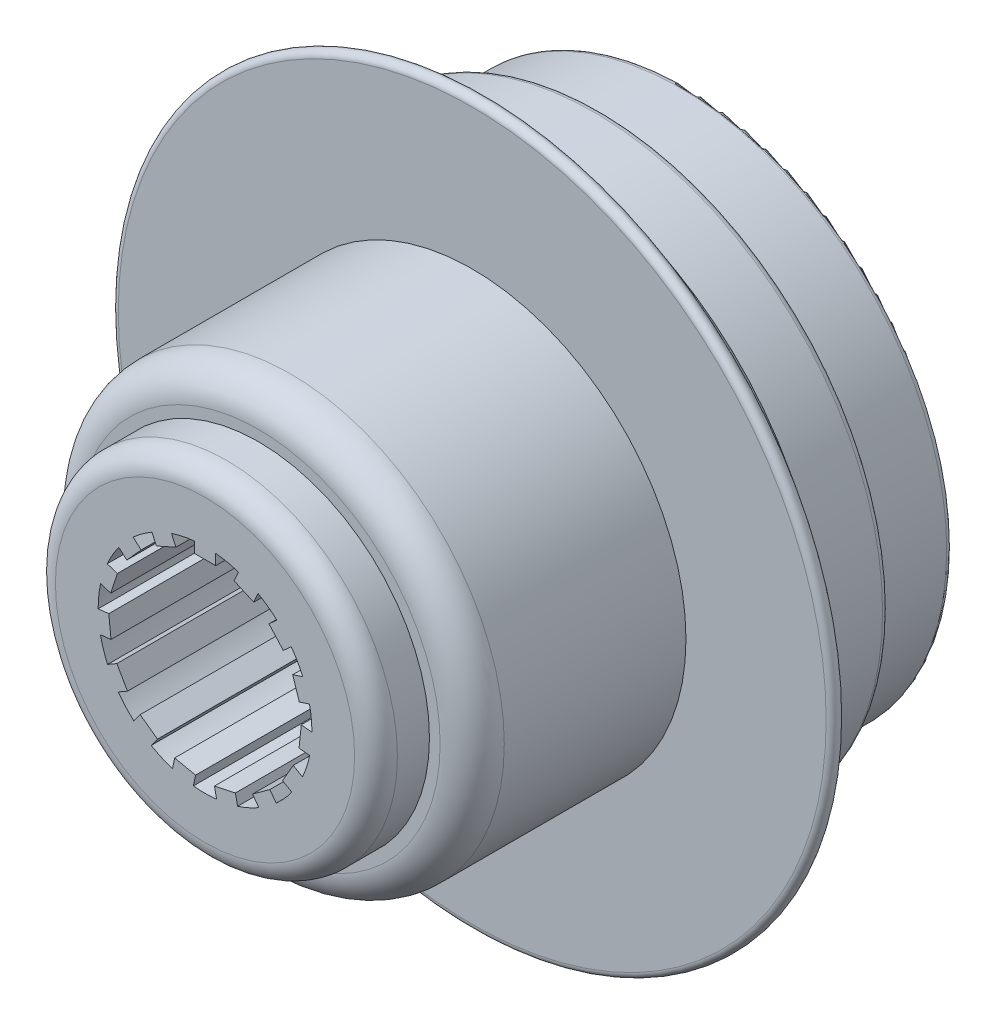
from build123d import *

# Parameters (mm, degrees)
SKETCH2_R          = 19.05
CUT_EXTRUDE1_DEPTH = 10.16
CUT_EXTRUDE4_DEPTH = 35.56


with BuildPart() as part:
    # Sketch1 → Revolve1 (revolve)
    with BuildSketch(Plane(origin=(0, 0, 0), x_dir=(0, 0, -1), z_dir=(1, 0, 0))):
        with BuildLine():
            Line((25.4, 0), (25.4, 30.988))
            ThreePointArc((25.4, 30.988), (25.176815367, 31.526815367), (24.638, 31.75))
            Line((24.638, 31.75), (15.24, 31.75))
            Line((15.24, 31.75), (15.24, 33.528))
            ThreePointArc((15.24, 33.528), (15.016815367, 34.066815367), (14.478, 34.29))
            Line((14.478, 34.29), (7.405874804, 34.29))
            Line((7.405874804, 34.29), (1.376457823, 42.511060606))
            ThreePointArc((1.376457823, 42.511060606), (0.52490599, 42.784586117), (0, 42.060410427))
            Line((0, 42.060410427), (0, 25.4))
            Line((0, 25.4), (-21.59, 25.4))
            ThreePointArc((-21.59, 25.4), (-24.284076836, 24.284076836), (-25.4, 21.59))
            Line((-25.4, 21.59), (-25.4, 20.32))
            Line((-25.4, 20.32), (-29.21, 20.32))
            ThreePointArc((-29.21, 20.32), (-31.006051224, 19.576051224), (-31.75, 17.78))
            Line((-31.75, 17.78), (-31.75, 0))
            Line((-31.75, 0), (25.4, 0))
        make_face()
    revolve(axis=Axis((0, 0, 0), (0, 0, -1)))

    # Sketch2 → Cut-Extrude1 (cut)
    with BuildSketch(Plane(origin=(0, 0, -25.4), x_dir=(-1, 0, 0), z_dir=(0, 0, -1))):
        Circle(SKETCH2_R)
    extrude(amount=-CUT_EXTRUDE1_DEPTH, mode=Mode.SUBTRACT)

    # Sketch3 → Cut-Extrude4 (cut)
    with BuildSketch(Plane.XY.offset(31.75)):
        with BuildLine():
            Line((-1.27, 11.366340451), (1.27, 11.366340451))
            Line((1.27, 11.366340451), (1.27, 12.636340451))
            ThreePointArc((1.27, 12.636340451), (2.640478473, 12.422474529), (3.979459965, 12.060426957))
            Line((3.979459965, 12.060426957), (3.462904428, 10.900224226))
            Line((3.462904428, 10.900224226), (5.78330989, 9.867113153))
            Line((5.78330989, 9.867113153), (6.299865427, 11.027315884))
            ThreePointArc((6.299865427, 11.027315884), (7.464872704, 10.274515829), (8.540835149, 9.399156077))
            Line((8.540835149, 9.399156077), (7.597041221, 8.549360207))
            Line((7.597041221, 8.549360207), (9.296632961, 6.66177235))
            Line((9.296632961, 6.66177235), (10.240426889, 7.51156822))
            ThreePointArc((10.240426889, 7.51156822), (10.998522628, 6.35), (11.625422345, 5.112685722))
            Line((11.625422345, 5.112685722), (10.41758057, 4.720234139))
            Line((10.41758057, 4.720234139), (11.202483735, 2.304550588))
            Line((11.202483735, 2.304550588), (12.410325511, 2.69700217))
            ThreePointArc((12.410325511, 2.69700217), (12.630428071, 1.327511483), (12.699868404, -0.057814442))
            Line((12.699868404, -0.057814442), (11.436825597, 0.074936707))
            Line((11.436825597, 0.074936707), (11.171323301, -2.451148907))
            Line((11.171323301, -2.451148907), (12.434366108, -2.583900056))
            ThreePointArc((12.434366108, -2.583900056), (12.078417757, -3.924515829), (11.578391842, -5.218317963))
            Line((11.578391842, -5.218317963), (10.478539579, -4.583317963))
            Line((10.478539579, -4.583317963), (9.208539579, -6.783022488))
            Line((9.208539579, -6.783022488), (10.308391842, -7.418022488))
            ThreePointArc((10.308391842, -7.418022488), (9.437939284, -8.497958701), (8.454906143, -9.476526901))
            Line((8.454906143, -9.476526901), (7.708418873, -8.449075319))
            Line((7.708418873, -8.449075319), (5.653515707, -9.942049859))
            Line((5.653515707, -9.942049859), (6.400002977, -10.969501442))
            ThreePointArc((6.400002977, -10.969501442), (5.165555367, -11.602027312), (3.869490362, -12.096158247))
            Line((3.869490362, -12.096158247), (3.605442515, -10.853910794))
            Line((3.605442515, -10.853910794), (1.120947609, -11.382006489))
            Line((1.120947609, -11.382006489), (1.384995456, -12.624253942))
            ThreePointArc((1.384995456, -12.624253942), (0, -12.7), (-1.384995456, -12.624253942))
            Line((-1.384995456, -12.624253942), (-1.120947609, -11.382006489))
            Line((-1.120947609, -11.382006489), (-3.605442515, -10.853910794))
            Line((-3.605442515, -10.853910794), (-3.869490362, -12.096158247))
            ThreePointArc((-3.869490362, -12.096158247), (-5.165555367, -11.602027312), (-6.400002977, -10.969501442))
            Line((-6.400002977, -10.969501442), (-5.653515707, -9.942049859))
            Line((-5.653515707, -9.942049859), (-7.708418873, -8.449075319))
            Line((-7.708418873, -8.449075319), (-8.454906143, -9.476526901))
            ThreePointArc((-8.454906143, -9.476526901), (-9.437939284, -8.497958701), (-10.308391842, -7.418022488))
            Line((-10.308391842, -7.418022488), (-9.208539579, -6.783022488))
            Line((-9.208539579, -6.783022488), (-10.478539579, -4.583317963))
            Line((-10.478539579, -4.583317963), (-11.578391842, -5.218317963))
            ThreePointArc((-11.578391842, -5.218317963), (-12.078417757, -3.924515829), (-12.434366108, -2.583900056))
            Line((-12.434366108, -2.583900056), (-11.171323301, -2.451148907))
            Line((-11.171323301, -2.451148907), (-11.436825597, 0.074936707))
            Line((-11.436825597, 0.074936707), (-12.699868404, -0.057814442))
            ThreePointArc((-12.699868404, -0.057814442), (-12.630428071, 1.327511483), (-12.410325511, 2.69700217))
            Line((-12.410325511, 2.69700217), (-11.202483735, 2.304550588))
            Line((-11.202483735, 2.304550588), (-10.41758057, 4.720234139))
            Line((-10.41758057, 4.720234139), (-11.625422345, 5.112685722))
            ThreePointArc((-11.625422345, 5.112685722), (-10.998522628, 6.35), (-10.240426889, 7.51156822))
            Line((-10.240426889, 7.51156822), (-9.296632961, 6.66177235))
            Line((-9.296632961, 6.66177235), (-7.597041221, 8.549360207))
            Line((-7.597041221, 8.549360207), (-8.540835149, 9.399156077))
            ThreePointArc((-8.540835149, 9.399156077), (-7.464872704, 10.274515829), (-6.299865427, 11.027315884))
            Line((-6.299865427, 11.027315884), (-5.78330989, 9.867113153))
            Line((-5.78330989, 9.867113153), (-3.462904428, 10.900224226))
            Line((-3.462904428, 10.900224226), (-3.979459965, 12.060426957))
            ThreePointArc((-3.979459965, 12.060426957), (-2.640478473, 12.422474529), (-1.27, 12.636340451))
            Line((-1.27, 12.636340451), (-1.27, 11.366340451))
        make_face()
    extrude(amount=-CUT_EXTRUDE4_DEPTH, mode=Mode.SUBTRACT)


solid = part.part
